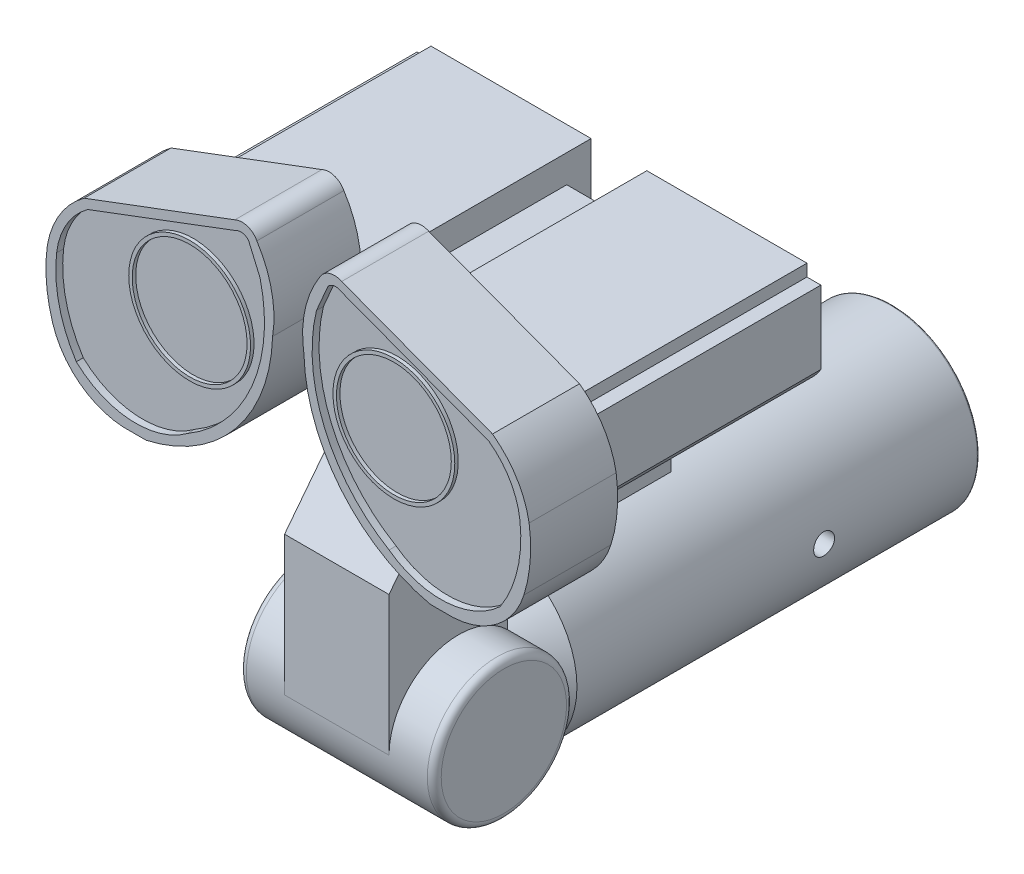
from build123d import *

# Parameters (mm, degrees)
SKETCH3_R                                 = 1
HINGE_CONNECTED_TO_BOTTOM_TUBE_DEPTH      = 1.4
HINGE_CONNECTED_TO_BOTTOM_TUBE_DEPTH_BACK = 1.4
FILLET_ON_HINGE_R                         = 0.1
BASE_CONNECTED_TO_EYES_DEPTH              = 0.75
BASE_CONNECTED_TO_EYES_DEPTH_BACK         = 0.75
EYE_BACKING_DEPTH                         = 3.5
SKETCH7_W                                 = 0.8
SKETCH7_H                                 = 3.5
EYE_BACKING_DETAILS_DEPTH                 = 1.07
SKETCH8_W                                 = 0.8
SKETCH8_H                                 = 1.9
MIDDLE_OF_EYE_BACKING_DEPTH               = 0.67
SKETCH12_R                                = 0.875
OUTER_EYE_DEPTH                           = 1.25
INNER_EYE_CUT_DEPTH                       = 0.1
SKETCH12_5_R                              = 0.875
SKETCH12_5_R_2                            = 0.825
OUTER_LENS_DEPTH                          = 1.2
SKETCH12_7_R                              = 0.825
INNER_LENS_CUT_DEPTH                      = 1.15
CUT_EXTRUDE3_REACH                        = 5.481
SKETCH15_R                                = 0.15
CUT_EXTRUDE3_DIRECTION_2_REACH            = 5.481
SKETCH12_6_R                              = 0.825
BOSS_EXTRUDE16_DEPTH                      = 1.15


with BuildPart() as part:
    # Sketch2 → Bottom tube (revolve)
    with BuildSketch(Plane(origin=(0, 0, 0), x_dir=(0, 0, -1), z_dir=(1, 0, 0))):
        Polygon((0, 0), (0, 1.25), (-5.75, 1.25), (-6.25, 0.75), (-6.25, 0), align=None)
        with BuildLine():
            add(Edge.make_bspline(
                [(0.163609492, 0), (0.163609492, 1.25), (0, 1.25)],
                knots=[4.71238898, 4.71238898, 4.71238898, 6.283185307, 6.283185307, 6.283185307], degree=2, weights=[1, 0.707106781, 1]))
            Line((0, 1.25), (0, 0))
            Line((0, 0), (0.163609492, 0))
        make_face()
    revolve(axis=Axis((0, 0, 6.25), (0, 0, -1)))

    # Sketch3 → Hinge connected to bottom tube (add, two sides)
    with BuildSketch(Plane(origin=(0, 0, 0), x_dir=(0, 0, -1), z_dir=(1, 0, 0))) as hinge_connected_to_bottom_tube_sk:
        with Locations((-6.95, 0)):
            Circle(SKETCH3_R)
    extrude(amount=HINGE_CONNECTED_TO_BOTTOM_TUBE_DEPTH)
    extrude(hinge_connected_to_bottom_tube_sk.sketch, amount=-HINGE_CONNECTED_TO_BOTTOM_TUBE_DEPTH_BACK)

    # fillet on hinge
    fillet_on_hinge_edges = [part.edges().sort_by_distance(p)[0] for p in [
        (-1.4, 0, 7.95),
        (1.4, 0, 7.95),
    ]]
    fillet(fillet_on_hinge_edges, radius=FILLET_ON_HINGE_R)

    # Sketch4 → base connected to eyes (add, two sides)
    with BuildSketch(Plane(origin=(0, 0, 0), x_dir=(0, 0, -1), z_dir=(1, 0, 0))) as base_connected_to_eyes_sk:
        with BuildLine():
            Line((-7.95, 0), (-7.95, 2))
            Line((-7.95, 2), (-6.39677242, 4))
            Line((-6.39677242, 4), (-3.89677242, 4))
            Line((-3.89677242, 4), (-3.89677242, 1.5))
            Line((-3.89677242, 1.5), (-6.25, 1.5))
            Line((-6.25, 1.5), (-6.25, 0.714142843))
            ThreePointArc((-6.25, 0.714142843), (-7.337298335, 0.921954446), (-7.95, 0))
        make_face()
    extrude(amount=BASE_CONNECTED_TO_EYES_DEPTH)
    extrude(base_connected_to_eyes_sk.sketch, amount=-BASE_CONNECTED_TO_EYES_DEPTH_BACK)

    # Sketch5 → Eye backing (add)
    with BuildSketch(Plane(origin=(0, 0, 3.89677242), x_dir=(-1, 0, 0), z_dir=(0, 0, -1))):
        with BuildLine():
            Line((0.75, 3.5), (2.25, 3.5))
            ThreePointArc((2.25, 3.5), (2.62408667, 3.581702047), (2.9, 3.847197614))
            Line((2.9, 3.847197614), (2.9, 4.897197614))
            Line((2.9, 4.897197614), (2.7, 4.897197614))
            Line((2.7, 4.897197614), (2.7, 5.07))
            Line((2.7, 5.07), (-2.7, 5.07))
            Line((-2.7, 5.07), (-2.7, 4.897197614))
            Line((-2.7, 4.897197614), (-2.9, 4.897197614))
            Line((-2.9, 4.897197614), (-2.9, 3.847197614))
            ThreePointArc((-2.9, 3.847197614), (-2.62408667, 3.581702047), (-2.25, 3.5))
            Line((-2.25, 3.5), (-0.75, 3.5))
            Line((-0.75, 3.5), (-0.75, 4))
            Line((-0.75, 4), (0.75, 4))
            Line((0.75, 4), (0.75, 3.5))
        make_face()
    extrude(amount=-EYE_BACKING_DEPTH)

    # Sketch7 → Eye backing details (cut)
    with BuildSketch(Plane(origin=(0, 5.07, 0), x_dir=(1, 0, 0), z_dir=(0, 1, 0))):
        with Locations((0, -5.64677242)):
            Rectangle(SKETCH7_W, SKETCH7_H)
    extrude(amount=-EYE_BACKING_DETAILS_DEPTH, mode=Mode.SUBTRACT)

    # Sketch8 → Middle of eye backing (add)
    with BuildSketch(Plane(origin=(0, 4, 0), x_dir=(1, 0, 0), z_dir=(0, 1, 0))):
        with Locations((0, -5.19677242)):
            Rectangle(SKETCH8_W, SKETCH8_H)
    extrude(amount=MIDDLE_OF_EYE_BACKING_DEPTH)

    # Sketch12 → Outer eye (add)
    with BuildSketch(Plane.XY.offset(7.39677242)):
        with BuildLine():
            ThreePointArc((-0.450961505, 6.145644801), (-0.587867618, 6.261837628), (-0.767083386, 6.250623109))
            Line((-0.767083386, 6.250623109), (-2.933329516, 5.436310045))
            ThreePointArc((-2.933329516, 5.436310045), (-3.278345677, 5.065387345), (-3.459739663, 4.592401064))
            ThreePointArc((-3.459739663, 4.592401064), (-3.474536987, 4.120986543), (-3.384350783, 3.658042637))
            ThreePointArc((-3.384350783, 3.658042637), (-3.001009551, 3.106292928), (-2.371698574, 2.871035758))
            Line((-2.371698574, 2.871035758), (-2.041485898, 2.871035758))
            ThreePointArc((-2.041485898, 2.871035758), (-1.426030829, 3.103911019), (-0.900550716, 3.5))
            Line((-0.900550716, 3.5), (-2.25, 3.5))
            ThreePointArc((-2.25, 3.5), (-2.62408667, 3.581702047), (-2.9, 3.847197614))
            Line((-2.9, 3.847197614), (-2.9, 4.897197614))
            Line((-2.9, 4.897197614), (-2.7, 4.897197614))
            Line((-2.7, 4.897197614), (-2.7, 5.07))
            Line((-2.7, 5.07), (-2.279609228, 5.07))
            ThreePointArc((-2.279609228, 5.07), (-1.466642551, 5.621410471), (-0.653675875, 5.07))
            Line((-0.653675875, 5.07), (-0.4, 5.07))
            Line((-0.4, 5.07), (-0.4, 4.252303124))
            ThreePointArc((-0.4, 4.252303124), (-0.275571311, 4.653228748), (-0.225316176, 5.07))
            ThreePointArc((-0.225316176, 5.07), (-0.238383659, 5.628748724), (-0.450961505, 6.145644801))
        make_face()
        with BuildLine():
            ThreePointArc((-0.75, 3.6667336), (-0.628965774, 3.828416623), (-0.522430198, 4))
            Line((-0.522430198, 4), (-0.75, 4))
            Line((-0.75, 4), (-0.75, 3.6667336))
        make_face()
        with BuildLine():
            ThreePointArc((-0.522430198, 4), (-0.45740495, 4.124302685), (-0.4, 4.252303124))
            Line((-0.4, 4.252303124), (-0.4, 5.07))
            Line((-0.4, 5.07), (-0.653675875, 5.07))
            ThreePointArc((-0.653675875, 5.07), (-0.607290807, 4.911151417), (-0.591642551, 4.746410471))
            ThreePointArc((-0.591642551, 4.746410471), (-1.631383497, 3.887058726), (-2.279609228, 5.07))
            Line((-2.279609228, 5.07), (-2.7, 5.07))
            Line((-2.7, 5.07), (-2.7, 4.897197614))
            Line((-2.7, 4.897197614), (-2.9, 4.897197614))
            Line((-2.9, 4.897197614), (-2.9, 3.847197614))
            ThreePointArc((-2.9, 3.847197614), (-2.62408667, 3.581702047), (-2.25, 3.5))
            Line((-2.25, 3.5), (-0.900550716, 3.5))
            ThreePointArc((-0.900550716, 3.5), (-0.823259036, 3.581546179), (-0.75, 3.6667336))
            Line((-0.75, 3.6667336), (-0.75, 4))
            Line((-0.75, 4), (-0.522430198, 4))
        make_face()
        with BuildLine():
            ThreePointArc((2.933329516, 5.436310045), (3.278345677, 5.065387345), (3.459739663, 4.592401064))
            ThreePointArc((3.459739663, 4.592401064), (3.474536987, 4.120986543), (3.384350783, 3.658042637))
            ThreePointArc((3.384350783, 3.658042637), (3.001009551, 3.106292928), (2.371698574, 2.871035758))
            Line((2.371698574, 2.871035758), (2.041485898, 2.871035758))
            ThreePointArc((2.041485898, 2.871035758), (0.756304939, 3.659066468), (0.225316176, 5.07))
            ThreePointArc((0.225316176, 5.07), (0.238383659, 5.628748724), (0.450961505, 6.145644801))
            ThreePointArc((0.450961505, 6.145644801), (0.587867618, 6.261837628), (0.767083386, 6.250623109))
            Line((0.767083386, 6.250623109), (2.933329516, 5.436310045))
        make_face()
        with Locations((1.466642551, 4.746410471)):
            Circle(SKETCH12_R, mode=Mode.SUBTRACT)
    extrude(amount=OUTER_EYE_DEPTH)

    # Sketch13 → Inner eye cut (cut)
    with BuildSketch(Plane.XY.offset(8.64677242)):
        with BuildLine():
            Line((-0.757964351, 6.121312443), (-2.880162803, 5.322245904))
            ThreePointArc((-2.880162803, 5.322245904), (-3.184019481, 4.988025414), (-3.327634423, 4.55976502))
            ThreePointArc((-3.327634423, 4.55976502), (-3.29208127, 3.928007422), (-3.044809473, 3.345565711))
            ThreePointArc((-3.044809473, 3.345565711), (-2.263619647, 3.009419304), (-1.448470515, 3.251873102))
            ThreePointArc((-1.448470515, 3.251873102), (-0.52016025, 4.307569927), (-0.404930121, 5.708633007))
            Line((-0.404930121, 5.708633007), (-0.570058708, 6.091643131))
            ThreePointArc((-0.570058708, 6.091643131), (-0.658423401, 6.141869268), (-0.757964351, 6.121312443))
        make_face()
        with BuildLine():
            Line((0.570058708, 6.091643131), (0.404930121, 5.708633007))
            ThreePointArc((0.404930121, 5.708633007), (0.52016025, 4.307569927), (1.448470515, 3.251873102))
            ThreePointArc((1.448470515, 3.251873102), (2.263619647, 3.009419304), (3.044809473, 3.345565711))
            ThreePointArc((3.044809473, 3.345565711), (3.29208127, 3.928007422), (3.327634423, 4.55976502))
            ThreePointArc((3.327634423, 4.55976502), (3.184019481, 4.988025414), (2.880162803, 5.322245904))
            Line((2.880162803, 5.322245904), (0.757964351, 6.121312443))
            ThreePointArc((0.757964351, 6.121312443), (0.658423401, 6.141869268), (0.570058708, 6.091643131))
        make_face()
    extrude(amount=-INNER_EYE_CUT_DEPTH, mode=Mode.SUBTRACT)

    # Sketch12_5 → Outer lens (add)
    with BuildSketch(Plane.XY.offset(7.39677242)):
        with BuildLine():
            ThreePointArc((-2.279609228, 5.07), (-1.631383497, 3.887058726), (-0.591642551, 4.746410471))
            ThreePointArc((-0.591642551, 4.746410471), (-0.607290807, 4.911151417), (-0.653675875, 5.07))
            Line((-0.653675875, 5.07), (-0.707752034, 5.07))
            ThreePointArc((-0.707752034, 5.07), (-0.658338872, 4.911547268), (-0.641642551, 4.746410471))
            ThreePointArc((-0.641642551, 4.746410471), (-1.631779348, 3.938106792), (-2.225533068, 5.07))
            Line((-2.225533068, 5.07), (-2.279609228, 5.07))
        make_face()
        with BuildLine():
            Line((-0.707752034, 5.07), (-0.653675875, 5.07))
            ThreePointArc((-0.653675875, 5.07), (-1.466642551, 5.621410471), (-2.279609228, 5.07))
            Line((-2.279609228, 5.07), (-2.225533068, 5.07))
            ThreePointArc((-2.225533068, 5.07), (-1.466642551, 5.571410471), (-0.707752034, 5.07))
        make_face()
        with Locations((1.466642551, 4.746410471)):
            Circle(SKETCH12_5_R)
        with Locations((1.466642551, 4.746410471)):
            Circle(SKETCH12_5_R_2, mode=Mode.SUBTRACT)
    extrude(amount=OUTER_LENS_DEPTH)

    # Sketch12_7 → Inner lens cut (add)
    with BuildSketch(Plane.XY.offset(7.39677242)):
        with BuildLine():
            Line((-2.225533068, 5.07), (-0.707752034, 5.07))
            ThreePointArc((-0.707752034, 5.07), (-1.466642551, 5.571410471), (-2.225533068, 5.07))
        make_face()
        with BuildLine():
            ThreePointArc((-0.641642551, 4.746410471), (-0.658338872, 4.911547268), (-0.707752034, 5.07))
            Line((-0.707752034, 5.07), (-2.225533068, 5.07))
            ThreePointArc((-2.225533068, 5.07), (-1.631779348, 3.938106792), (-0.641642551, 4.746410471))
        make_face()
        with Locations((1.466642551, 4.746410471)):
            Circle(SKETCH12_7_R)
    extrude(amount=INNER_LENS_CUT_DEPTH)

    # Sketch15 → Cut-Extrude3 (cut, up to next)
    with BuildSketch(Plane(origin=(0, 0, 0), x_dir=(0, 0, -1), z_dir=(1, 0, 0)), mode=Mode.PRIVATE) as cut_extrude3_sk1:
        with Locations((-2.2, 0)):
            Circle(SKETCH15_R)
    cut_extrude3_tool1 = extrude(cut_extrude3_sk1.sketch, amount=-CUT_EXTRUDE3_REACH, mode=Mode.PRIVATE) & part.part
    add(cut_extrude3_tool1.solids().sort_by_distance((0, 0, 2.2))[0], mode=Mode.SUBTRACT)

    # Sketch15 → Cut-Extrude3 direction 2 (cut, up to next)
    with BuildSketch(Plane(origin=(0, 0, 0), x_dir=(0, 0, -1), z_dir=(1, 0, 0)), mode=Mode.PRIVATE) as cut_extrude3_direction_2_sk1:
        with Locations((-2.2, 0)):
            Circle(SKETCH15_R)
    cut_extrude3_direction_2_tool1 = extrude(cut_extrude3_direction_2_sk1.sketch, amount=CUT_EXTRUDE3_DIRECTION_2_REACH, mode=Mode.PRIVATE) & part.part
    add(cut_extrude3_direction_2_tool1.solids().sort_by_distance((0, 0, 2.2))[0], mode=Mode.SUBTRACT)

    # Sketch12_6 → Boss-Extrude16 (add)
    with BuildSketch(Plane.XY.offset(7.39677242)):
        with BuildLine():
            Line((-2.225533068, 5.07), (-0.707752034, 5.07))
            ThreePointArc((-0.707752034, 5.07), (-1.466642551, 5.571410471), (-2.225533068, 5.07))
        make_face()
        with BuildLine():
            ThreePointArc((-0.641642551, 4.746410471), (-0.658338872, 4.911547268), (-0.707752034, 5.07))
            Line((-0.707752034, 5.07), (-2.225533068, 5.07))
            ThreePointArc((-2.225533068, 5.07), (-1.631779348, 3.938106792), (-0.641642551, 4.746410471))
        make_face()
        with Locations((1.466642551, 4.746410471)):
            Circle(SKETCH12_6_R)
    extrude(amount=BOSS_EXTRUDE16_DEPTH)


solid = part.part
